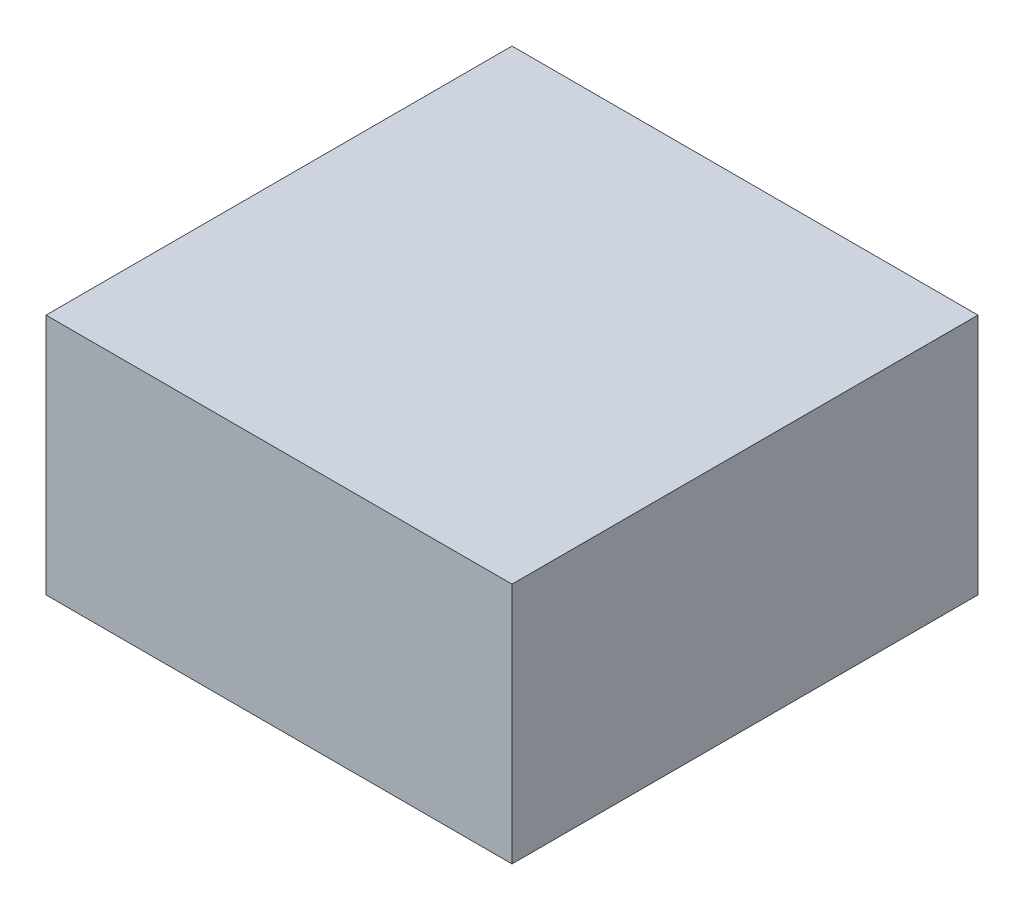
from build123d import *

# Parameters (mm, degrees)
SKETCH1_W           = 25
SKETCH1_H           = 25
BOSS_EXTRUDE1_DEPTH = 13


with BuildPart() as part:
    # Sketch1 → Boss-Extrude1 (new body)
    with BuildSketch(Plane(origin=(0, 0, 0), x_dir=(1, 0, 0), z_dir=(0, 1, 0))):
        with Locations((12.5, 12.5)):
            Rectangle(SKETCH1_W, SKETCH1_H)
    extrude(amount=BOSS_EXTRUDE1_DEPTH)


solid = part.part
